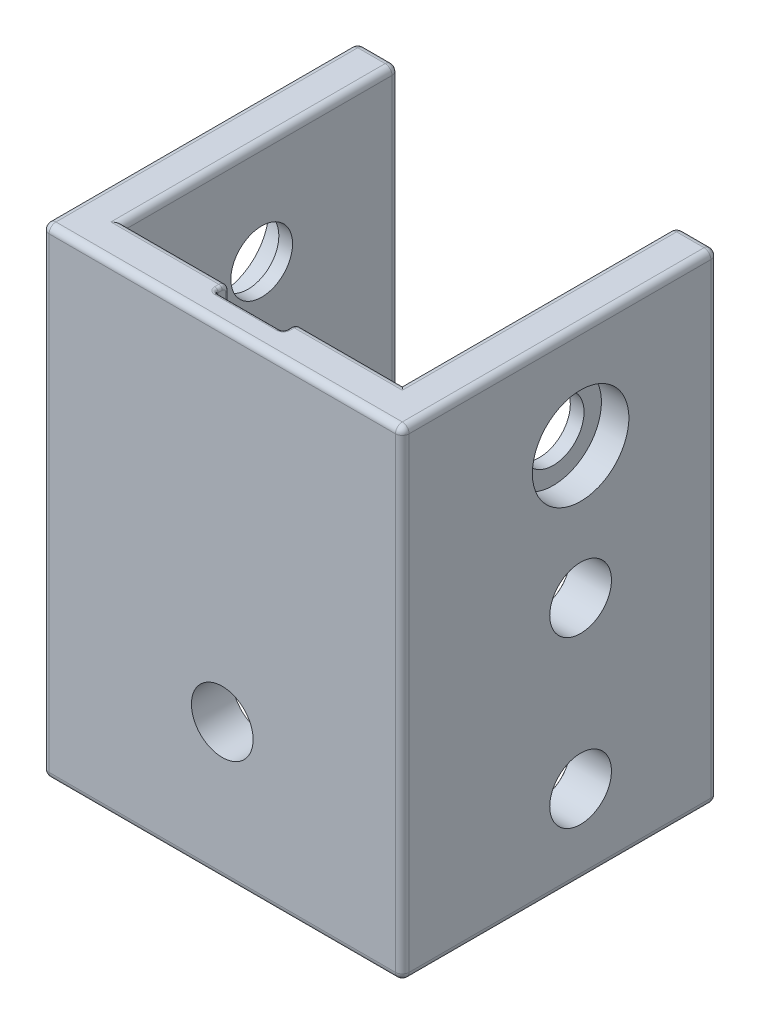
from build123d import *

# Parameters (mm, degrees)
BOSS_EXTRUDE1_DEPTH           = 70
SKETCH8_R                     = 4.5
CUT_EXTRUDE4_DEPTH            = 53.5
SKETCH10_R                    = 7.035
CUT_EXTRUDE5_DEPTH            = 4
FILLET13_R                    = 1
M8_CLEARANCE_HOLE1_AT_2_COUNT = 2
M8_CLEARANCE_HOLE1_AT_2_PITCH = 24.109474775
CUT_EXTRUDE6_REACH            = 54.5
SKETCH21_W                    = 30
SKETCH21_H                    = 26.5
M8_CLEARANCE_HOLE2_D          = 9
FILLET14_R                    = 5
SKETCH24_W                    = 10
SKETCH24_H                    = 38
CUT_EXTRUDE7_DEPTH            = 2.1
FILLET15_R                    = 0.5


with BuildPart() as part:
    # Sketch1 → Boss-Extrude1 (new body)
    with BuildSketch(Plane(origin=(0, 0, 0), x_dir=(1, 0, 0), z_dir=(0, 1, 0))):
        Polygon((-26.25, -26.25), (26.25, -26.25), (26.25, 19.75), (20.25, 19.75), (20.25, -20.25), (-20.25, -20.25), (-20.25, 19.75), (-26.25, 19.75), align=None)
    extrude(amount=BOSS_EXTRUDE1_DEPTH)

    # Sketch8 → Cut-Extrude4 (cut, through all)
    with BuildSketch(Plane(origin=(26.25, 0, 0), x_dir=(0, 0, -1), z_dir=(1, 0, 0))):
        with Locations((-0.25, 55)):
            Circle(SKETCH8_R)
    extrude(amount=-CUT_EXTRUDE4_DEPTH, mode=Mode.SUBTRACT)

    # Sketch10 → Cut-Extrude5 (cut)
    with BuildSketch(Plane.ZY.offset(26.25)):
        with Locations((0.25, 55)):
            Circle(SKETCH10_R)
    cut_extrude5 = extrude(amount=-CUT_EXTRUDE5_DEPTH, mode=Mode.SUBTRACT)

    # Mirror1: Cut-Extrude5 across plane
    add(cut_extrude5.mirror(Plane(origin=(0, 0, 0), x_dir=(0, 0, 1), z_dir=(1, 0, 0))), mode=Mode.SUBTRACT)

    # Fillet13
    fillet13_edges = [part.edges().sort_by_distance(p)[0] for p in [
        (26.25, 0, 3.25),
        (0, 0, 26.25),
        (0, 70, 20.25),
        (-26.25, 0, 3.25),
        (-23.25, 0, -19.75),
        (-20.25, 0, 0.25),
        (0, 0, 20.25),
        (20.25, 0, 0.25),
        (-20.25, 70, 0.25),
        (20.25, 35, -19.75),
        (26.25, 35, -19.75),
        (26.25, 35, 26.25),
        (-26.25, 35, 26.25),
        (-26.25, 35, -19.75),
        (-20.25, 35, -19.75),
        (-23.25, 70, -19.75),
        (-26.25, 70, 3.25),
        (0, 70, 26.25),
        (26.25, 70, 3.25),
        (23.25, 70, -19.75),
        (20.25, 70, 0.25),
        (23.25, 0, -19.75),
    ]]
    fillet(fillet13_edges, radius=FILLET13_R)

    # Sketch18 → M8 Clearance Hole1 (revolve, cut)
    with BuildSketch(Plane(origin=(-20.25, 35.786178525, 0.25), x_dir=(0, 0, -1), z_dir=(0, 1, 0))):
        Polygon((0, 0), (0, 15.703872786), (4.5, 13), (4.5, 0.025), (4.525, 0), align=None)
    m8_clearance_hole1 = revolve(axis=Axis((-13.9, 35.786178525, 0.25), (-1, 0, 0)), mode=Mode.SUBTRACT)

    # M8 Clearance Hole1 at 2: M8 Clearance Hole1 ×2
    with Locations(*[(0, -i * M8_CLEARANCE_HOLE1_AT_2_PITCH, 0) for i in range(1, M8_CLEARANCE_HOLE1_AT_2_COUNT)]):
        add(m8_clearance_hole1, mode=Mode.SUBTRACT)

    # Mirror2: M8 Clearance Hole1 across plane
    add(m8_clearance_hole1.mirror(Plane(origin=(0, 0, 0), x_dir=(0, 0, 1), z_dir=(1, 0, 0))), mode=Mode.SUBTRACT)

    # Mirror2 copy 1 sketch → Mirror2 copy 1 (revolve, cut)
    with BuildSketch(Plane(origin=(20.25, 11.676703751, 0.25), x_dir=(0, 0, -1), z_dir=(0, 1, 0))):
        Polygon((0, 0), (0, -15.703872786), (4.5, -13), (4.5, -0.025), (4.525, 0), align=None)
    revolve(axis=Axis((13.9, 11.676703751, 0.25), (-1, 0, 0)), mode=Mode.SUBTRACT)

    # Sketch21 → Cut-Extrude6 (cut, up to next)
    with BuildSketch(Plane.ZY.offset(26.25), mode=Mode.PRIVATE) as cut_extrude6_sk1:
        with Locations((-4.75, 13.25)):
            Rectangle(SKETCH21_W, SKETCH21_H)
    cut_extrude6_tool1 = extrude(cut_extrude6_sk1.sketch, amount=-CUT_EXTRUDE6_REACH, mode=Mode.PRIVATE) & part.part
    add(cut_extrude6_tool1.solids().sort_by_distance((-26.25, 13.25, -4.75))[0], mode=Mode.SUBTRACT)

    # M8 Clearance Hole2 (through all)
    with Locations(Plane.XY.offset(26.25)):
        with Locations((0, 20)):
            Hole(M8_CLEARANCE_HOLE2_D / 2)

    # Fillet14
    fillet14_edges = [part.edges().sort_by_distance(p)[0] for p in [
        (-23.25, 26.5, 10.25),
    ]]
    fillet(fillet14_edges, radius=FILLET14_R)

    # Sketch24 → Cut-Extrude7 (cut)
    with BuildSketch(Plane(origin=(0, 0, 20.25), x_dir=(-1, 0, 0), z_dir=(0, 0, -1))):
        with Locations((0, 51)):
            Rectangle(SKETCH24_W, SKETCH24_H)
    extrude(amount=-CUT_EXTRUDE7_DEPTH, mode=Mode.SUBTRACT)

    # Fillet15
    fillet15_edges = [part.edges().sort_by_distance(p)[0] for p in [
        (5, 69.707106781, 20.542893219),
        (-5, 69.707106781, 20.542893219),
        (5, 70, 21.8),
        (0, 70, 22.35),
        (5, 50.5, 20.25),
        (0, 32, 20.25),
        (-5, 50.5, 20.25),
        (-5, 51, 22.35),
        (-5, 70, 21.8),
        (0, 32, 22.35),
        (-5, 32, 21.3),
        (5, 51, 22.35),
        (5, 32, 21.3),
    ]]
    fillet(fillet15_edges, radius=FILLET15_R)


solid = part.part
